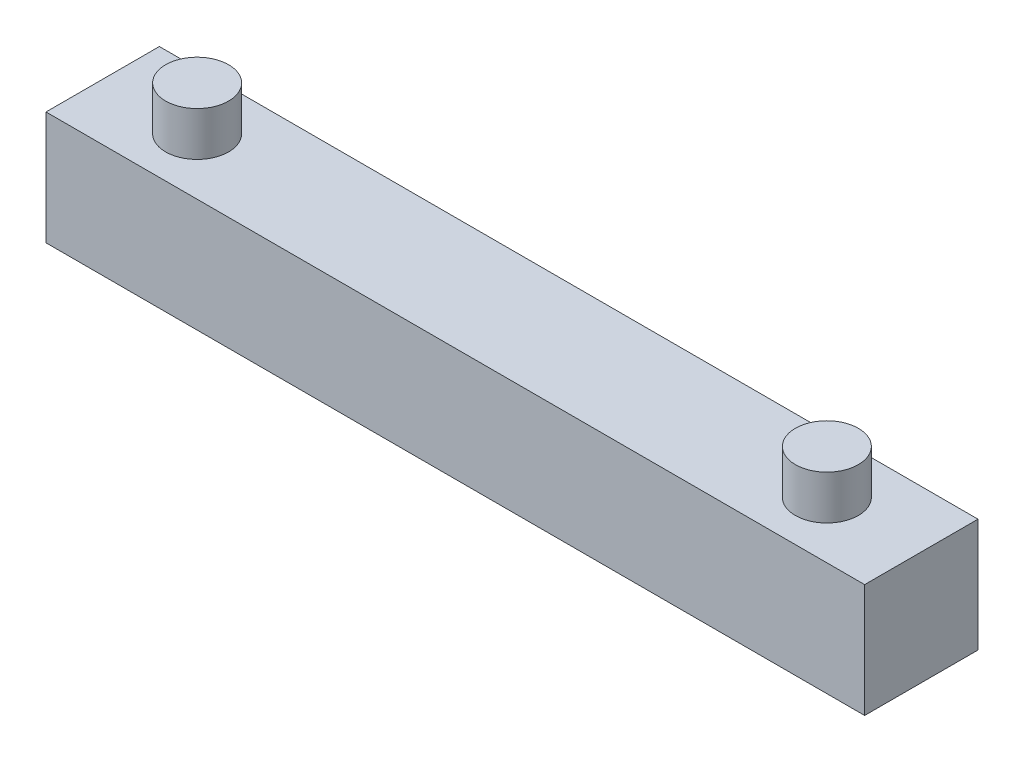
from build123d import *

# Parameters (mm, degrees)
SKETCH2_W           = 65
SKETCH2_H           = 9
BOSS_EXTRUDE1_DEPTH = 9
SKETCH3_R           = 2.5
BOSS_EXTRUDE2_DEPTH = 3.5
SKETCH4_R           = 2.5
BOSS_EXTRUDE3_DEPTH = 3.5


with BuildPart() as part:
    # Sketch2 → Boss-Extrude1 (new body)
    with BuildSketch(Plane(origin=(0, 0, 0), x_dir=(1, 0, 0), z_dir=(0, 1, 0))):
        Rectangle(SKETCH2_W, SKETCH2_H)
    extrude(amount=BOSS_EXTRUDE1_DEPTH)

    # Sketch3 → Boss-Extrude2 (add)
    with BuildSketch(Plane(origin=(0, 9, 0), x_dir=(1, 0, 0), z_dir=(0, 1, 0))):
        with Locations((-25, 0)):
            Circle(SKETCH3_R)
    extrude(amount=BOSS_EXTRUDE2_DEPTH)

    # Sketch4 → Boss-Extrude3 (add)
    with BuildSketch(Plane(origin=(0, 9, 0), x_dir=(1, 0, 0), z_dir=(0, 1, 0))):
        with Locations((25, 0)):
            Circle(SKETCH4_R)
    extrude(amount=BOSS_EXTRUDE3_DEPTH)


solid = part.part
